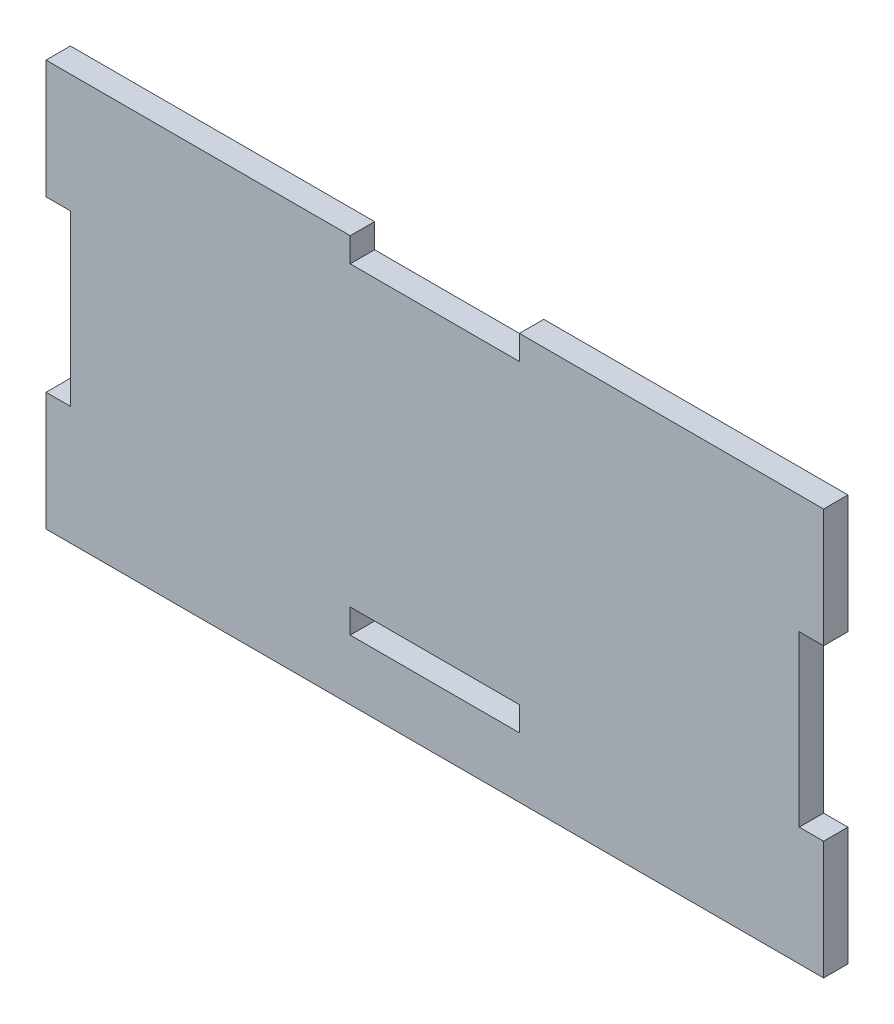
from build123d import *

# Parameters (mm, degrees)
SKETCH1_W           = 87.5284
SKETCH1_H           = 45.72
SKETCH1_W_2         = 19.05
SKETCH1_H_2         = 2.7432
BOSS_EXTRUDE1_DEPTH = 2.7432
SKETCH2_W           = 2.7432
SKETCH2_H           = 19.05
SKETCH2_W_2         = 19.05
SKETCH2_H_2         = 2.7432
CUT_EXTRUDE1_DEPTH  = 3.7432


with BuildPart() as part:
    # Sketch1 → Boss-Extrude1 (new body)
    with BuildSketch(Plane.XY):
        Rectangle(SKETCH1_W, SKETCH1_H)
        with Locations((0, -14.7066)):
            Rectangle(SKETCH1_W_2, SKETCH1_H_2, mode=Mode.SUBTRACT)
    extrude(amount=BOSS_EXTRUDE1_DEPTH)

    # Sketch2 → Cut-Extrude1 (cut, through all)
    with BuildSketch(Plane.XY.offset(2.7432)):
        with Locations((-42.3926, 0)):
            Rectangle(SKETCH2_W, SKETCH2_H)
        with Locations((42.3926, 0)):
            Rectangle(SKETCH2_W, SKETCH2_H)
        with Locations((0, 21.4884)):
            Rectangle(SKETCH2_W_2, SKETCH2_H_2)
    extrude(amount=-CUT_EXTRUDE1_DEPTH, mode=Mode.SUBTRACT)


solid = part.part
